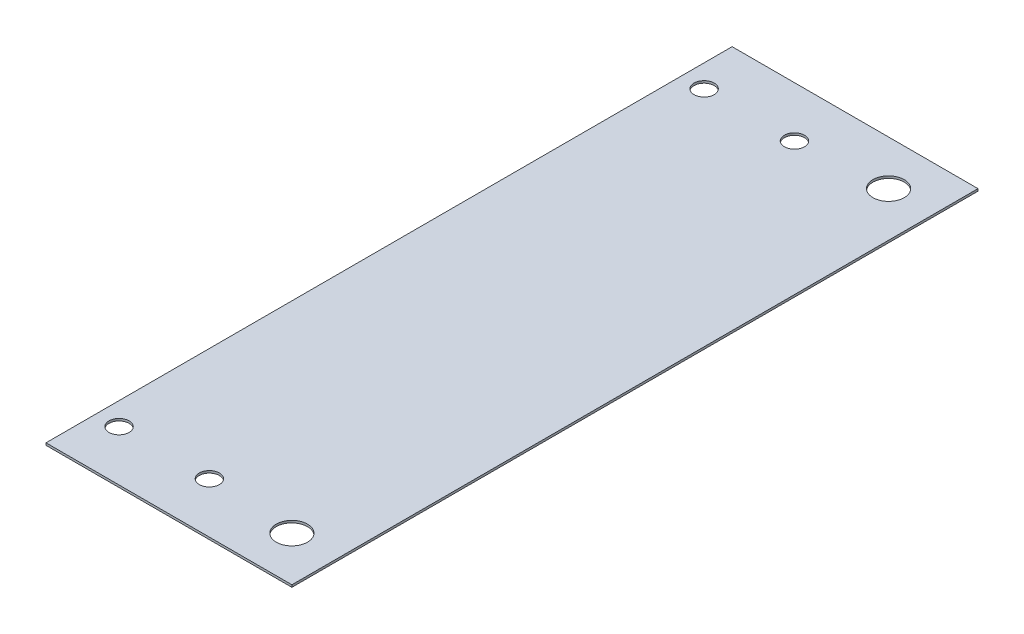
from build123d import *

# Parameters (mm, degrees)
SKETCH1_W           = 27.5
SKETCH1_H           = 76.735
SKETCH1_R           = 1.125
SKETCH1_R_2         = 1.75
BOSS_EXTRUDE1_DEPTH = 0.25


with BuildPart() as part:
    # Sketch1 → Boss-Extrude1 (new body)
    with BuildSketch(Plane(origin=(0, 0, 0), x_dir=(1, 0, 0), z_dir=(0, 1, 0))):
        Rectangle(SKETCH1_W, SKETCH1_H)
        with Locations(Location((-11.23, 32.7175, 0), (0, 0, 270))):  # turned: the seam where the file's is
            Circle(SKETCH1_R, mode=Mode.SUBTRACT)
        with Locations(Location((-1.13, 32.7175, 0), (0, 0, 270))):  # turned: the seam where the file's is
            Circle(SKETCH1_R, mode=Mode.SUBTRACT)
        with Locations(Location((8.75, 33.3675, 0), (0, 0, 270))):  # turned: the seam where the file's is
            Circle(SKETCH1_R_2, mode=Mode.SUBTRACT)
        with Locations(Location((8.75, -33.3675, 0), (0, 0, 270))):  # turned: the seam where the file's is
            Circle(SKETCH1_R_2, mode=Mode.SUBTRACT)
        with Locations(Location((-11.23, -32.7175, 0), (0, 0, 270))):  # turned: the seam where the file's is
            Circle(SKETCH1_R, mode=Mode.SUBTRACT)
        with Locations(Location((-1.13, -32.7175, 0), (0, 0, 270))):  # turned: the seam where the file's is
            Circle(SKETCH1_R, mode=Mode.SUBTRACT)
    extrude(amount=BOSS_EXTRUDE1_DEPTH)


solid = part.part
